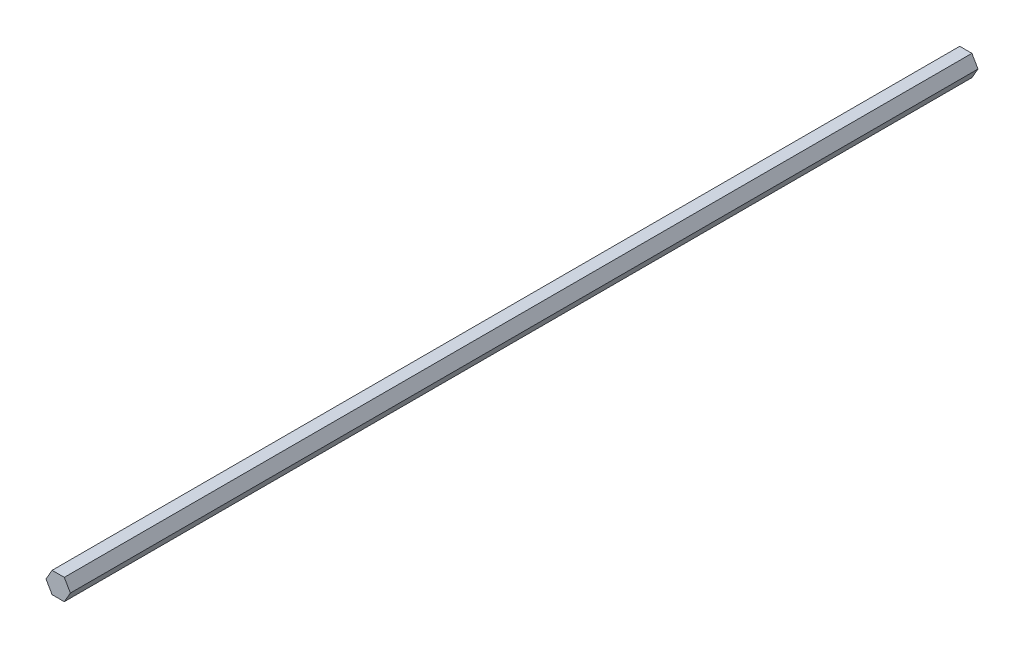
from build123d import *

# Parameters (mm, degrees)
BOSS_EXTRUDE1_DEPTH      = 508
BOSS_EXTRUDE1_DEPTH_BACK = 38.1


with BuildPart() as part:
    # Sketch1 → Boss-Extrude1 (new body, two sides)
    with BuildSketch(Plane.XY) as boss_extrude1_sk:
        Polygon((7.332348419, 0), (3.666174209, 6.35), (-3.666174209, 6.35), (-7.332348419, 0), (-3.666174209, -6.35), (3.666174209, -6.35), align=None)
    extrude(amount=BOSS_EXTRUDE1_DEPTH)
    extrude(boss_extrude1_sk.sketch, amount=-BOSS_EXTRUDE1_DEPTH_BACK)


solid = part.part
